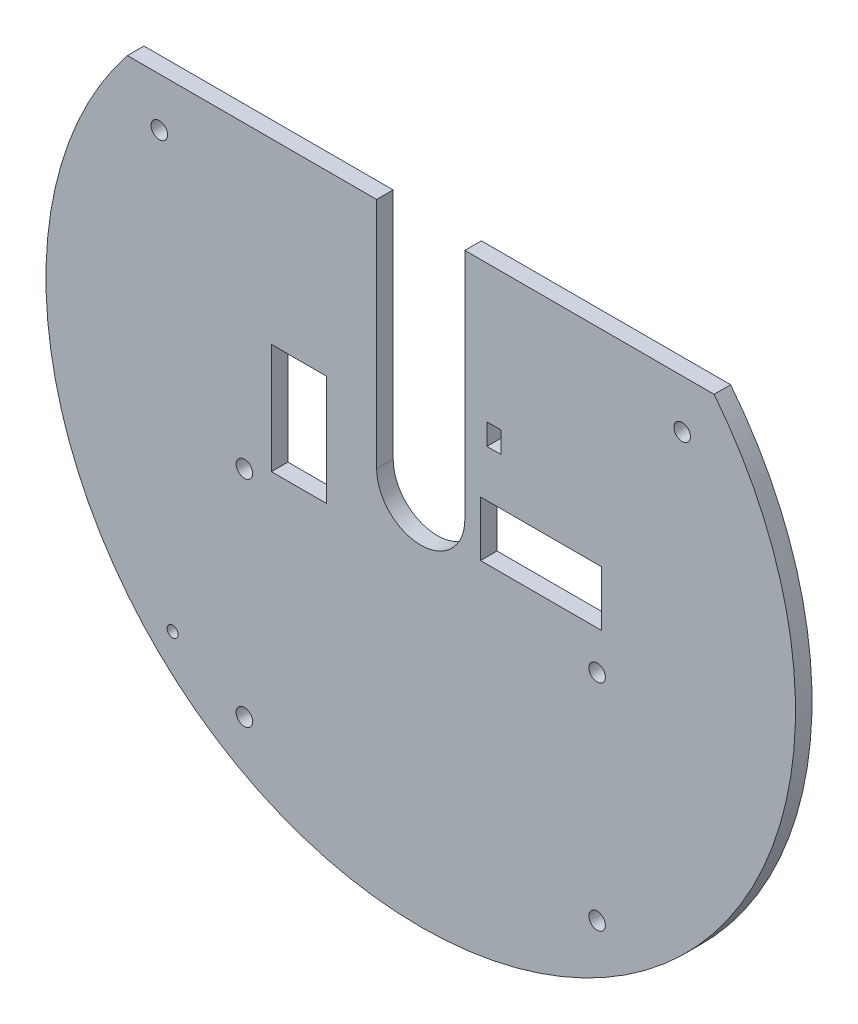
from build123d import *

# Parameters (mm, degrees)
SKETCH1_R           = 1.5
SKETCH1_R_2         = 1
SKETCH1_W           = 22
SKETCH1_H           = 10
SKETCH1_W_2         = 10
SKETCH1_H_2         = 20
BOSS_EXTRUDE2_DEPTH = 3
SKETCH2_W           = 2.6
SKETCH2_H           = 3.861185889
CUT_EXTRUDE1_DEPTH  = 3


with BuildPart() as part:
    # Sketch1 → Boss-Extrude2 (new body)
    with BuildSketch(Plane.XY):
        with BuildLine():
            Line((53.226921663, 42.318965137), (8, 42.318965137))
            Line((8, 42.318965137), (8, 0))
            ThreePointArc((8, 0), (0, -8), (-8, 0))
            Line((-8, 0), (-8, 42.318965137))
            Line((-8, 42.318965137), (-53.226921663, 42.318965137))
            ThreePointArc((-53.226921663, 42.318965137), (0, -68), (53.226921663, 42.318965137))
        make_face()
        with Locations((47.430328075, 33.5)):
            Circle(SKETCH1_R, mode=Mode.SUBTRACT)
        with Locations((-47.430328075, 33.5)):
            Circle(SKETCH1_R, mode=Mode.SUBTRACT)
        with Locations((-45.012826675, -44.077720389)):
            Circle(SKETCH1_R_2, mode=Mode.SUBTRACT)
        with Locations((-32, -12)):
            Circle(SKETCH1_R, mode=Mode.SUBTRACT)
        with Locations((-32, -51)):
            Circle(SKETCH1_R, mode=Mode.SUBTRACT)
        with Locations((32, -51)):
            Circle(SKETCH1_R, mode=Mode.SUBTRACT)
        with Locations((32, -12)):
            Circle(SKETCH1_R, mode=Mode.SUBTRACT)
        with Locations((21.843785427, 0)):
            Rectangle(SKETCH1_W, SKETCH1_H, mode=Mode.SUBTRACT)
        with Locations((-22.094715098, 0)):
            Rectangle(SKETCH1_W_2, SKETCH1_H_2, mode=Mode.SUBTRACT)
    extrude(amount=BOSS_EXTRUDE2_DEPTH)

    # Sketch2 → Cut-Extrude1 (cut)
    with BuildSketch(Plane.XY.offset(3)):
        with Locations((13.3, 15.449558082)):
            Rectangle(SKETCH2_W, SKETCH2_H)
    extrude(amount=-CUT_EXTRUDE1_DEPTH, mode=Mode.SUBTRACT)


solid = part.part
